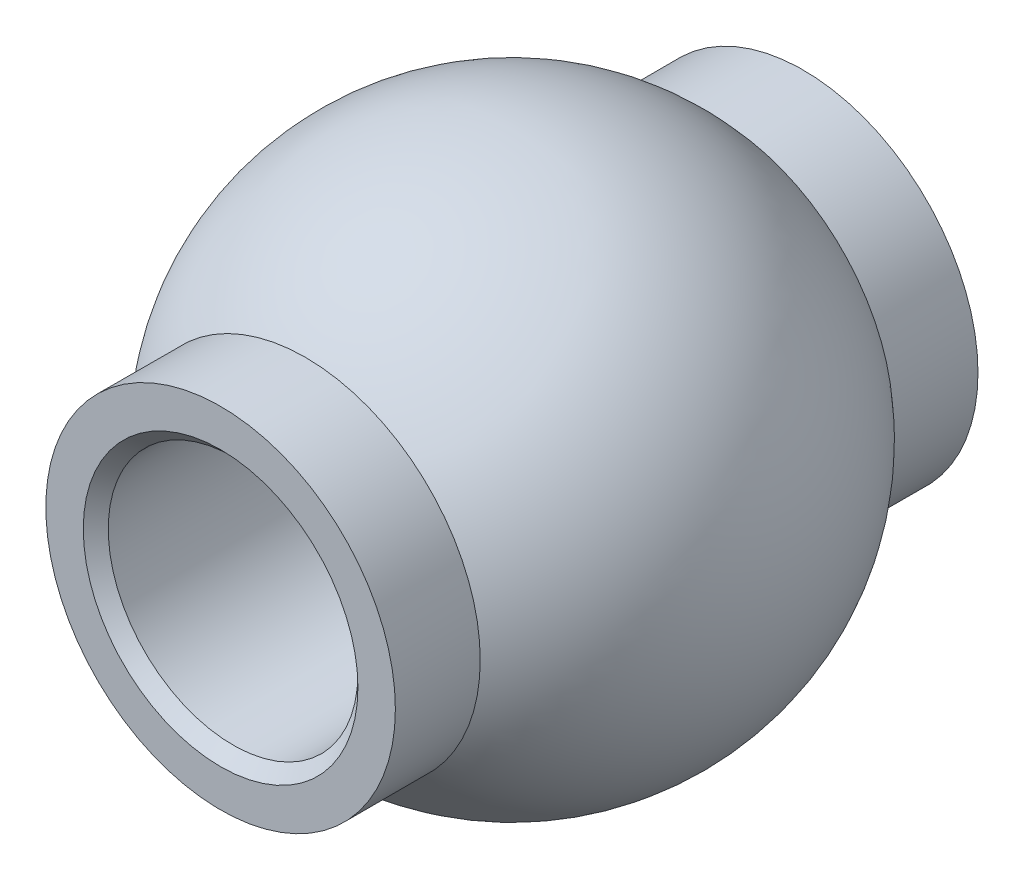
from build123d import *

# Parameters (mm, degrees)
SKETCH10_R              = 4.7625
CUT_EXTRUDE4_DEPTH      = 11.31875
CUT_EXTRUDE4_DEPTH_BACK = 11.31875
SKETCH12_R              = 6.6675
SKETCH12_R_2            = 4.7625
EXTRUDE1_DEPTH          = 11.1125
EXTRUDE1_DEPTH_BACK     = 11.1125
CHAMFER1_SIZE           = 0.47625


with BuildPart() as part:
    # Sketch7 → Revolve3 (revolve)
    with BuildSketch(Plane.XY):
        with BuildLine():
            Line((0, 29.36875), (0, 8.73125))
            ThreePointArc((0, 8.73125), (10.31875, 19.05), (0, 29.36875))
        make_face()
    revolve(axis=Axis((0, 0, 0), (0, 1, 0)))

    # Sketch10 → Cut-Extrude4 (cut, two sides)
    with BuildSketch(Plane.XY) as cut_extrude4_sk:
        with Locations((0, 19.05)):
            Circle(SKETCH10_R)
    extrude(amount=CUT_EXTRUDE4_DEPTH, mode=Mode.SUBTRACT)
    extrude(cut_extrude4_sk.sketch, amount=-CUT_EXTRUDE4_DEPTH_BACK, mode=Mode.SUBTRACT)

    # Sketch12 → Extrude1 (add, two sides)
    with BuildSketch(Plane.XY) as extrude1_sk:
        with Locations((0, 19.05)):
            Circle(SKETCH12_R)
        with Locations((0, 19.05)):
            Circle(SKETCH12_R_2, mode=Mode.SUBTRACT)
    extrude(amount=EXTRUDE1_DEPTH)
    extrude(extrude1_sk.sketch, amount=-EXTRUDE1_DEPTH_BACK)

    # Chamfer1
    chamfer1_edges = [part.edges().sort_by_distance(p)[0] for p in [
        (-4.7625, 19.05, 11.1125),
        (-4.7625, 19.05, -11.1125),
    ]]
    chamfer(chamfer1_edges, length=CHAMFER1_SIZE)


solid = part.part
